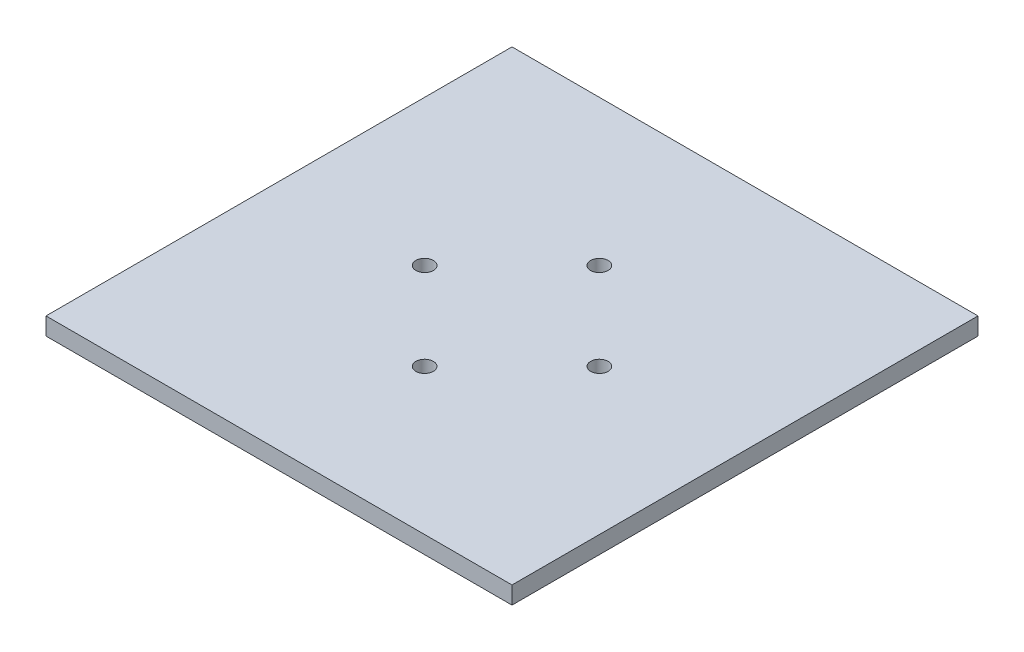
from build123d import *

# Parameters (mm, degrees)
SKETCH_1_W      = 80
SKETCH_1_H      = 80
SKETCH_1_R      = 1.5
EXTRUDE_1_DEPTH = 3


with BuildPart() as part:
    # 草图1 → 凸台-拉伸1 (new body)
    with BuildSketch(Plane(origin=(0, 0, 0), x_dir=(1, 0, 0), z_dir=(0, 1, 0))):
        Rectangle(SKETCH_1_W, SKETCH_1_H)
        with Locations((0, 15)):
            Circle(SKETCH_1_R, mode=Mode.SUBTRACT)
        with Locations((15, 0)):
            Circle(SKETCH_1_R, mode=Mode.SUBTRACT)
        with Locations((0, -15)):
            Circle(SKETCH_1_R, mode=Mode.SUBTRACT)
        with Locations((-15, 0)):
            Circle(SKETCH_1_R, mode=Mode.SUBTRACT)
    extrude(amount=EXTRUDE_1_DEPTH)


solid = part.part
